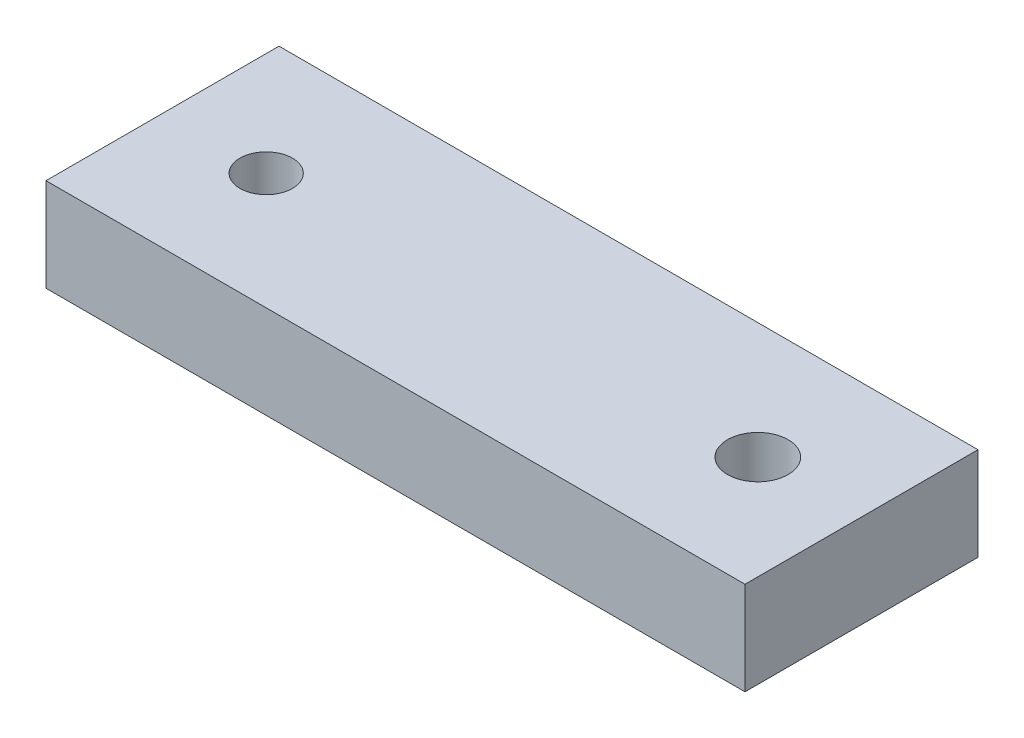
from build123d import *

# Parameters (mm, degrees)
SKETCH_1_W          = 60
SKETCH_1_H          = 20
EXTRUDE_1_DEPTH     = 8
SKETCH_2_R          = 2.254482182
SKETCH_2_R_2        = 2.6
CUT_EXTRUDE_1_DEPTH = 9


with BuildPart() as part:
    # 草图1 → 凸台-拉伸1 (new body)
    with BuildSketch(Plane(origin=(0, 0, 0), x_dir=(1, 0, 0), z_dir=(0, 1, 0))):
        with Locations((-4.829444607, -4.251986222)):
            Rectangle(SKETCH_1_W, SKETCH_1_H)
    extrude(amount=EXTRUDE_1_DEPTH)

    # 草图2 → 切除-拉伸1 (cut, through all)
    with BuildSketch(Plane(origin=(0, 8, 0), x_dir=(1, 0, 0), z_dir=(0, 1, 0))):
        with Locations((-25.929444607, -4.251986222)):
            Circle(SKETCH_2_R)
        with Locations((16.270555393, -4.251986222)):
            Circle(SKETCH_2_R_2)
    extrude(amount=-CUT_EXTRUDE_1_DEPTH, mode=Mode.SUBTRACT)


solid = part.part
